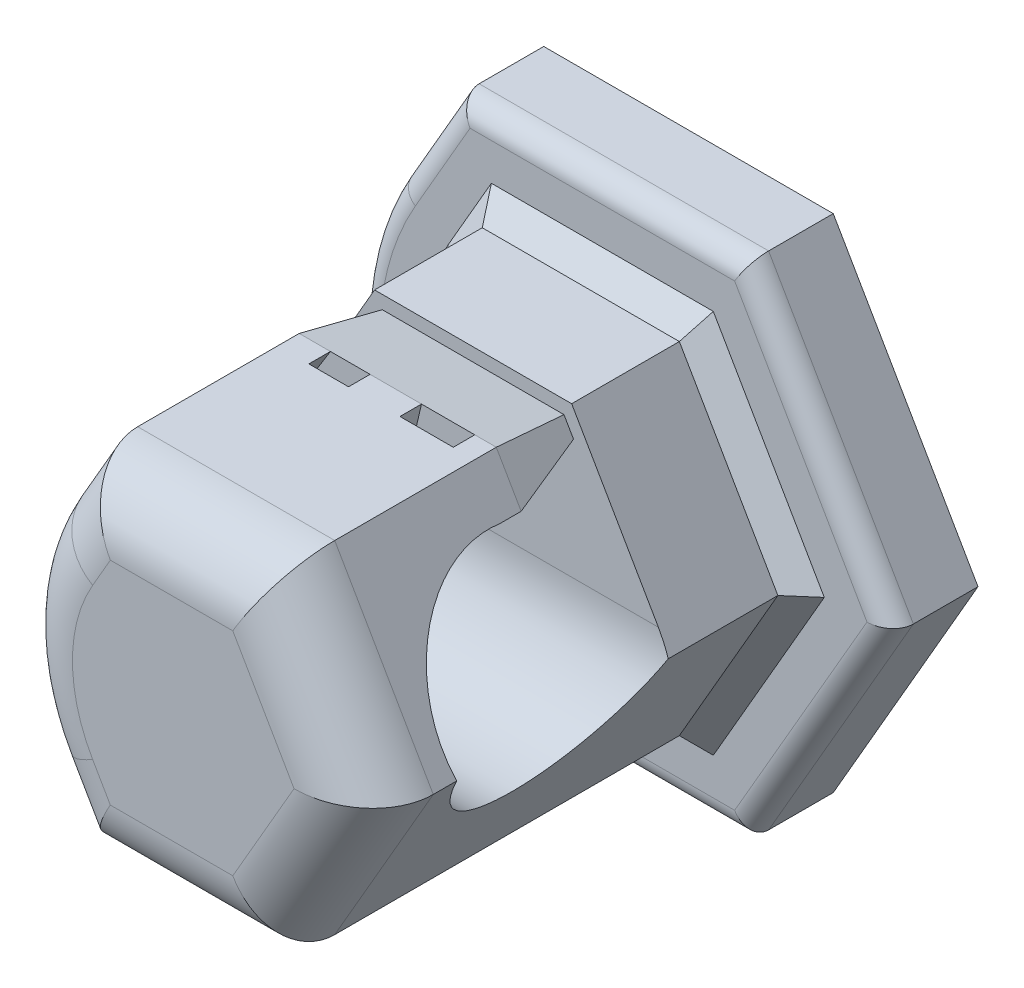
from build123d import *

# Parameters (mm, degrees)
BOSS_EXTRUDE1_DEPTH = 2
BOSS_EXTRUDE2_DEPTH = 10
FILLET1_R           = 5
FILLET3_R           = 1.5
CHAMFER2_SIZE       = 0.5
CUT_EXTRUDE3_DEPTH  = 0.5
CUT_EXTRUDE4_DEPTH  = 21.623479126
BOSS_EXTRUDE3_DEPTH = 0.5
BOSS_EXTRUDE4_DEPTH = 1.75
BOSS_EXTRUDE4_TAPER = 10
FILLET4_R           = 0.5


with BuildPart() as part:
    # Sketch1 → Boss-Extrude1 (new body)
    with BuildSketch(Plane.XY):
        with BuildLine():
            Line((-18.307344689, 6.635155065), (-19.719150501, 4.189835667))
            ThreePointArc((-19.719150501, 4.189835667), (-20.623479026, 0.814835667), (-19.719150501, -2.560164333))
            Line((-19.719150501, -2.560164333), (-18.307344689, -5.005483731))
            Line((-18.307344689, -5.005483731), (-11.586618746, -5.005483731))
            Line((-11.586618746, -5.005483731), (-8.226255775, 0.814835667))
            Line((-8.226255775, 0.814835667), (-11.586618746, 6.635155065))
            Line((-11.586618746, 6.635155065), (-18.307344689, 6.635155065))
        make_face()
    extrude(amount=BOSS_EXTRUDE1_DEPTH)

    # Sketch2 → Boss-Extrude2 (add)
    with BuildSketch(Plane.XY.offset(2)):
        Polygon((-10.371981717, 0.814835667), (-12.659481717, 4.776901889), (-17.234481717, 4.776901889), (-19.521981717, 0.814835667), (-17.234481717, -3.147230555), (-12.659481717, -3.147230555), align=None)
    extrude(amount=BOSS_EXTRUDE2_DEPTH)

    # Fillet1
    fillet1_edges = [part.edges().sort_by_distance(p)[0] for p in [
        (-19.521981717, 0.814835667, 7),
    ]]
    fillet(fillet1_edges, radius=FILLET1_R)

    # Fillet3
    fillet3_edges = [part.edges().sort_by_distance(p)[0] for p in [
        (-11.515731717, -1.166197444, 12),
        (-11.515731717, 2.795868778, 12),
        (-14.946981717, 4.776901889, 12),
        (-17.656543881, 4.045868778, 12),
        (-14.946981717, -3.147230555, 12),
        (-17.656543881, -2.416197444, 12),
        (-18.748479026, 0.814835667, 12),
    ]]
    fillet(fillet3_edges, radius=FILLET3_R)

    # Chamfer2
    chamfer2_edges = [part.edges().sort_by_distance(p)[0] for p in [
        (-11.515731717, -1.166197444, 2),
        (-11.515731717, 2.795868778, 2),
        (-14.946981717, 4.776901889, 2),
        (-17.656543881, 4.045868778, 2),
        (-14.946981717, -3.147230555, 2),
        (-17.656543881, -2.416197444, 2),
        (-18.748479026, 0.814835667, 2),
    ]]
    chamfer(chamfer2_edges, length=CHAMFER2_SIZE)

    # Sketch5 → Cut-Extrude3 (cut)
    with BuildSketch(Plane(origin=(0, 0, 0), x_dir=(-1, 0, 0), z_dir=(0, 0, -1))):
        with BuildLine():
            add(Edge.make_bspline(
                [(17.334786341, 0.218548778), (17.382057733, 0.173206522), (17.477451419, 0.081705832), (17.603723323, -0.074390404), (17.716327534, -0.247055984), (17.817336964, -0.436566287), (17.901274325, -0.65009172), (17.958452864, -0.891434605), (17.99158921, -1.161265343), (17.996284627, -1.350180774), (17.998749949, -1.449370526)],
                knots=[0, 0, 0, 0, 0.000196356, 0.000396247, 0.000600645, 0.000814045, 0.001039488, 0.001286872, 0.001556015, 0.001853547, 0.001853547, 0.001853547, 0.001853547], degree=3))
            add(Edge.make_bspline(
                [(17.998749949, -1.449370526), (17.995938061, -1.550370065), (17.99042273, -1.748473946), (17.949139803, -2.039940155), (17.877535623, -2.317684226), (17.779771985, -2.582057405), (17.655807042, -2.829887409), (17.511413342, -3.063500878), (17.341907306, -3.279829924), (17.212703317, -3.409849657), (17.147879695, -3.475082551)],
                knots=[0, 0, 0, 0, 0.000302946, 0.000594208, 0.000880881, 0.001161934, 0.001438171, 0.001710823, 0.001984663, 0.002260389, 0.002260389, 0.002260389, 0.002260389], degree=3))
            add(Edge.make_bspline(
                [(17.147879695, -3.475082551), (17.070377048, -3.542730737), (16.915446685, -3.677961706), (16.656557517, -3.849406164), (16.377572966, -3.991198864), (16.080987817, -4.108176079), (15.765825205, -4.193407758), (15.436481927, -4.258320539), (15.091588045, -4.295801738), (14.857026612, -4.300447874), (14.737673999, -4.302811981)],
                knots=[0, 0, 0, 0, 0.000308367, 0.000616437, 0.000928512, 0.001245848, 0.001571054, 0.001906543, 0.002252123, 0.002610132, 0.002610132, 0.002610132, 0.002610132], degree=3))
            add(Edge.make_bspline(
                [(14.737673999, -4.302811981), (14.612984766, -4.300966677), (14.364921261, -4.29729553), (13.994141061, -4.26122766), (13.62670291, -4.207130546), (13.267646988, -4.130482729), (12.927228743, -4.040664244), (12.613879239, -3.944547166), (12.331604322, -3.846508239), (12.157406773, -3.772086594), (12.074699316, -3.736751855)],
                knots=[0, 0, 0, 0, 0.000373966, 0.000743988, 0.00111657, 0.001487682, 0.001844748, 0.002172454, 0.002470847, 0.002740595, 0.002740595, 0.002740595, 0.002740595], degree=3))
            Line((12.074699316, -3.736751855), (12.074699316, -2.480027171))
            Line((12.074699316, -2.480027171), (12.165482544, -2.480027171))
            add(Edge.make_bspline(
                [(12.165482544, -2.480027171), (12.253770809, -2.535823846), (12.433849169, -2.649630294), (12.723319226, -2.800841675), (13.036128354, -2.935675762), (13.365993148, -3.054566841), (13.704027375, -3.155536589), (14.042072252, -3.22306025), (14.373863113, -3.269306295), (14.593337439, -3.274782447), (14.702072733, -3.277495526)],
                knots=[0, 0, 0, 0, 0.00031323, 0.000638885, 0.000978504, 0.001334374, 0.001690387, 0.00203565, 0.002367721, 0.002693784, 0.002693784, 0.002693784, 0.002693784], degree=3))
            add(Edge.make_bspline(
                [(14.702072733, -3.277495526), (14.766239609, -3.276352843), (14.897421818, -3.274016753), (15.095920053, -3.246912263), (15.300539826, -3.207851673), (15.506709599, -3.153861955), (15.707445344, -3.08520649), (15.891294645, -2.997122798), (16.057378565, -2.89725156), (16.152637237, -2.815431049), (16.199105961, -2.775517677)],
                knots=[0, 0, 0, 0, 0.000192379, 0.000393297, 0.000599969, 0.000817144, 0.0010322, 0.001235237, 0.001427887, 0.001611372, 0.001611372, 0.001611372, 0.001611372], degree=3))
            add(Edge.make_bspline(
                [(16.199105961, -2.775517677), (16.243542159, -2.730816936), (16.33069797, -2.643142256), (16.440332663, -2.496786928), (16.536201892, -2.347122065), (16.614672641, -2.187604991), (16.674157152, -2.012381712), (16.716027847, -1.818344602), (16.740582713, -1.603081491), (16.743868972, -1.4529972), (16.745585392, -1.374607867)],
                knots=[0, 0, 0, 0, 0.000188871, 0.000370447, 0.000547247, 0.000721593, 0.000902294, 0.001100969, 0.001316025, 0.001551162, 0.001551162, 0.001551162, 0.001551162], degree=3))
            add(Edge.make_bspline(
                [(16.745585392, -1.374607867), (16.74436603, -1.297347142), (16.742019984, -1.148697897), (16.710762919, -0.937077144), (16.663998012, -0.745295356), (16.595130054, -0.574898841), (16.511620962, -0.421829904), (16.410990308, -0.287595676), (16.296356665, -0.16961153), (16.208974519, -0.105457602), (16.165284759, -0.073381602)],
                knots=[0, 0, 0, 0, 0.000231579, 0.000445557, 0.000640269, 0.000822402, 0.000995297, 0.001161911, 0.001324288, 0.001486655, 0.001486655, 0.001486655, 0.001486655], degree=3))
            add(Edge.make_bspline(
                [(16.165284759, -0.073381602), (16.117907478, -0.043075997), (16.022153738, 0.018174353), (15.862417411, 0.088980172), (15.689421756, 0.14588131), (15.435558854, 0.202115245), (15.093847287, 0.24379374), (14.81434004, 0.250623742), (14.670031594, 0.254150044)],
                knots=[0, 0, 0, 0, 0.000168515, 0.000340583, 0.000522403, 0.00071413, 0.001119723, 0.001552644, 0.001552644, 0.001552644, 0.001552644], degree=3))
            Line((14.670031594, 0.254150044), (14.125332227, 0.254150044))
            Line((14.125332227, 0.254150044), (14.125332227, 1.2794665))
            Line((14.125332227, 1.2794665), (14.540086974, 1.2794665))
            add(Edge.make_bspline(
                [(14.540086974, 1.2794665), (14.613722817, 1.280072403), (14.757123621, 1.281252357), (14.965607245, 1.302490751), (15.163494078, 1.331257276), (15.349388109, 1.376450151), (15.524797468, 1.43092537), (15.688577055, 1.498595554), (15.839524795, 1.58146738), (15.98097968, 1.672973482), (16.107438693, 1.777724421), (16.217732001, 1.894763038), (16.31032378, 2.023816469), (16.388173619, 2.163678587), (16.446747218, 2.315993068), (16.487072761, 2.479319913), (16.512698778, 2.653465554), (16.51602425, 2.773439843), (16.51773729, 2.835241816)],
                knots=[0, 0, 0, 0, 0.000220792, 0.000429978, 0.00062811, 0.000820241, 0.001003207, 0.001178749, 0.00135079, 0.001519145, 0.001683471, 0.001842146, 0.002000241, 0.002158787, 0.002321095, 0.002488175, 0.00266263, 0.00284797, 0.00284797, 0.00284797, 0.00284797], degree=3))
            add(Edge.make_bspline(
                [(16.51773729, 2.835241816), (16.515956597, 2.889914816), (16.512510989, 2.995706052), (16.487859567, 3.149839351), (16.442770915, 3.292519067), (16.381900038, 3.425031855), (16.306627866, 3.547046091), (16.217394882, 3.658135293), (16.11322519, 3.756854739), (16.035430351, 3.812766925), (15.996178746, 3.840977576)],
                knots=[0, 0, 0, 0, 0.000164008, 0.000317351, 0.000466548, 0.000611511, 0.000753783, 0.000895563, 0.001037846, 0.001182744, 0.001182744, 0.001182744, 0.001182744], degree=3))
            add(Edge.make_bspline(
                [(15.996178746, 3.840977576), (15.953319459, 3.866740485), (15.867879746, 3.91809868), (15.731643627, 3.980045839), (15.591062925, 4.030033727), (15.392286141, 4.080850445), (15.121796264, 4.118848019), (14.899199164, 4.12456319), (14.782175581, 4.127567766)],
                knots=[0, 0, 0, 0, 0.000149917, 0.000298858, 0.000448055, 0.000597007, 0.000913698, 0.001264736, 0.001264736, 0.001264736, 0.001264736], degree=3))
            add(Edge.make_bspline(
                [(14.782175581, 4.127567766), (14.685934395, 4.125153084), (14.489129247, 4.120215262), (14.190163354, 4.079270347), (13.88250712, 4.011903762), (13.568414415, 3.922924282), (13.255330247, 3.806238181), (12.946650618, 3.672309581), (12.648196891, 3.513329881), (12.458390029, 3.391354897), (12.363069569, 3.330099411)],
                knots=[0, 0, 0, 0, 0.000288639, 0.000590243, 0.000903418, 0.001233018, 0.001568663, 0.001905019, 0.00224187, 0.002581695, 0.002581695, 0.002581695, 0.002581695], degree=3))
            Line((12.363069569, 3.330099411), (12.302547417, 3.330099411))
            Line((12.302547417, 3.330099411), (12.302547417, 4.586824095))
            add(Edge.make_bspline(
                [(12.302547417, 4.586824095), (12.379267588, 4.622217862), (12.542280072, 4.69742137), (12.810744884, 4.796024828), (13.11495317, 4.888747092), (13.447033142, 4.97822878), (13.794477018, 5.056841726), (14.144275141, 5.110562851), (14.488281117, 5.147161365), (14.715627692, 5.150986066), (14.828457227, 5.152884221)],
                knots=[0, 0, 0, 0, 0.000253395, 0.000538405, 0.000857081, 0.001207266, 0.001570054, 0.001925041, 0.002268483, 0.002606863, 0.002606863, 0.002606863, 0.002606863], degree=3))
            add(Edge.make_bspline(
                [(14.828457227, 5.152884221), (14.934709428, 5.151722537), (15.140957516, 5.149467571), (15.440598559, 5.126238777), (15.720498567, 5.087068812), (15.983237124, 5.034329537), (16.229841568, 4.96310762), (16.463297436, 4.873323987), (16.684529475, 4.766033218), (16.821721792, 4.678368405), (16.889770518, 4.634885804)],
                knots=[0, 0, 0, 0, 0.000318711, 0.000618656, 0.000900856, 0.001166175, 0.001421935, 0.001669869, 0.001915859, 0.002157954, 0.002157954, 0.002157954, 0.002157954], degree=3))
            add(Edge.make_bspline(
                [(16.889770518, 4.634885804), (16.959449101, 4.585029028), (17.095762514, 4.487493359), (17.272854357, 4.313279893), (17.42600056, 4.126062826), (17.55099269, 3.921564268), (17.650638189, 3.70122943), (17.721796513, 3.463763856), (17.76276285, 3.208100164), (17.768138254, 3.032384338), (17.770901847, 2.942045614)],
                knots=[0, 0, 0, 0, 0.000256687, 0.000502162, 0.000742635, 0.000980765, 0.001218981, 0.001466205, 0.001722268, 0.001993212, 0.001993212, 0.001993212, 0.001993212], degree=3))
            add(Edge.make_bspline(
                [(17.770901847, 2.942045614), (17.768912605, 2.879093839), (17.764995845, 2.755143641), (17.742274304, 2.571871729), (17.700423624, 2.395912824), (17.645307904, 2.224426843), (17.572662771, 2.059708347), (17.482287658, 1.901705371), (17.37677683, 1.749879597), (17.256687671, 1.605553068), (17.125469219, 1.470719575), (16.986512963, 1.34872554), (16.844011993, 1.236736424), (16.69391628, 1.139995527), (16.536551766, 1.059511688), (16.375991506, 0.98648468), (16.208436032, 0.929284753), (16.093159788, 0.902877733), (16.035340138, 0.889632639)],
                knots=[0, 0, 0, 0, 0.000188897, 0.000371932, 0.000552851, 0.000730733, 0.000911653, 0.001091817, 0.001276, 0.001465625, 0.001654446, 0.001839821, 0.002019986, 0.002197743, 0.002374498, 0.002549814, 0.00272657, 0.002904443, 0.002904443, 0.002904443, 0.002904443], degree=3))
            Line((16.035340138, 0.889632639), (16.035340138, 0.804189601))
            add(Edge.make_bspline(
                [(16.035340138, 0.804189601), (16.085347365, 0.794828116), (16.190419917, 0.775158255), (16.351115194, 0.729425543), (16.522984484, 0.672391478), (16.700682552, 0.602379068), (16.877977163, 0.522538139), (17.044992757, 0.432293576), (17.198548291, 0.332883496), (17.289817998, 0.256287448), (17.334786341, 0.218548778)],
                knots=[0, 0, 0, 0, 0.000152557, 0.000320544, 0.000500674, 0.000695703, 0.000893258, 0.001083624, 0.001264815, 0.00144079, 0.00144079, 0.00144079, 0.00144079], degree=3))
        make_face()
    extrude(amount=-CUT_EXTRUDE3_DEPTH, mode=Mode.SUBTRACT)

    # Sketch6 → Cut-Extrude4 (cut, through all)
    with BuildSketch(Plane(origin=(0, 0, 0), x_dir=(0, 0, -1), z_dir=(1, 0, 0))):
        with BuildLine():
            Line((-5, 4.776901889), (-5, 1.289433296))
            ThreePointArc((-5, 1.289433296), (-9.354049622, -0.387617687), (-7.25, 3.776901889))
            Line((-7.25, 3.776901889), (-7.25, 4.776901889))
            Line((-7.25, 4.776901889), (-5, 4.776901889))
        make_face()
    extrude(amount=-CUT_EXTRUDE4_DEPTH, mode=Mode.SUBTRACT)

    # Sketch7 → Boss-Extrude3 (add)
    with BuildSketch(Plane(origin=(0, 0, 7.25), x_dir=(-1, 0, 0), z_dir=(0, 0, -1))):
        Polygon((13.245432344, 3.776901889), (13.157791515, 4.776901889), (12.659481717, 4.776901889), (12.082131448, 3.776901889), align=None)
        Polygon((15.589379454, 4.776901889), (14.395255103, 4.776901889), (14.62732241, 3.776901889), (16.000903377, 3.776901889), align=None)
        Polygon((17.234481717, 4.776901889), (16.509588246, 4.776901889), (17.128441993, 3.776901889), (17.811831987, 3.776901889), align=None)
    extrude(amount=BOSS_EXTRUDE3_DEPTH)

    # Sketch8 → Boss-Extrude4 (add)
    with BuildSketch(Plane(origin=(0, 0, 6.75), x_dir=(-1, 0, 0), z_dir=(0, 0, -1))):
        Polygon((17.811831987, 3.776901889), (17.234481717, 4.776901889), (12.659481717, 4.776901889), (12.082131448, 3.776901889), align=None)
    extrude(amount=BOSS_EXTRUDE4_DEPTH, taper=BOSS_EXTRUDE4_TAPER)

    # Fillet4
    fillet4_edges = [part.edges().sort_by_distance(p)[0] for p in [
        (-20.623479026, 0.814835667, 2),
        (-19.013247595, -3.782824032, 2),
        (-14.946981717, -5.005483731, 2),
        (-9.906437261, -2.095324032, 2),
        (-9.906437261, 3.724995366, 2),
        (-14.946981717, 6.635155065, 2),
        (-19.013247595, 5.412495366, 2),
    ]]
    fillet(fillet4_edges, radius=FILLET4_R)


solid = part.part
